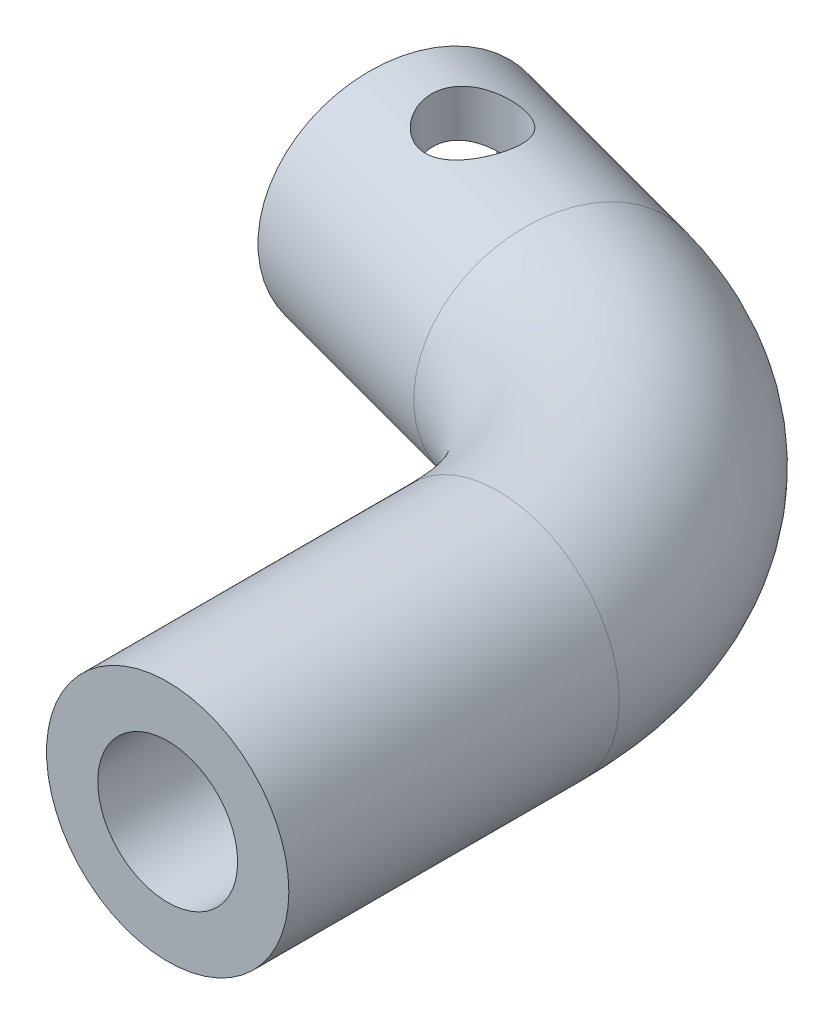
from build123d import *

# Parameters (mm, degrees)
SKETCH4_R           = 5.5
SKETCH6_R           = 3.175
HOLE_SHAFT_DEPTH    = 10
SKETCH7_R           = 3.4
HOLE_POT_DEPTH      = 10
SKETCH8_R           = 2
HOLE_INSERT_DEPTH   = 6.5000001
BOSS_EXTRUDE3_DEPTH = 1.5


with BuildPart() as part:
    # Sweep2: sweep along a path in PROFILE
    with BuildLine(Plane(origin=(0, 0, 0), x_dir=(1, 0, 0), z_dir=(0, 1, 0))) as sweep2_path:
        Line((2.5, -25), (2.5, -10))
        ThreePointArc((2.5, -10), (-0.172829853, -2.126097159), (-7.086656691, 2.49357424))
        Line((-7.086656691, 2.49357424), (-16.745914953, 5.081764691))
    # Sketch4 → Sweep2 (sweep)
    with BuildSketch(Plane.XY.offset(25)):
        with Locations((2.5, 0)):
            Circle(SKETCH4_R)
    sweep(path=sweep2_path.line)

    # Sketch6 → HOLE_SHAFT (cut)
    with BuildSketch(Plane.XY.offset(25)):
        with Locations((2.5, 0)):
            Circle(SKETCH6_R)
    extrude(amount=-HOLE_SHAFT_DEPTH, mode=Mode.SUBTRACT)

    # Sketch7 → HOLE_POT (cut)
    with BuildSketch(Plane(origin=(-16.894592529, 0, -4.526892425), x_dir=(-0.258819045, 0, 0.965925826), z_dir=(-0.965925826, 0, -0.258819045))):
        with Locations((-0.57444604, 0)):
            Circle(SKETCH7_R)
    extrude(amount=-HOLE_POT_DEPTH, mode=Mode.SUBTRACT)

    # Sketch8 → HOLE_INSERT (cut, through all)
    with BuildSketch(Plane(origin=(0, 0, 0), x_dir=(1, 0, 0), z_dir=(0, 1, 0))):
        with Locations((-12.643487424, 3.982522547)):
            Circle(SKETCH8_R)
    extrude(amount=HOLE_INSERT_DEPTH, mode=Mode.SUBTRACT)

    # Sketch11 → Boss-Extrude3 (add)
    with BuildSketch(Plane(origin=(-7.235334266, 0, -1.938701974), x_dir=(-0.258819045, 0, 0.965925826), z_dir=(-0.965925826, 0, -0.258819045))):
        with BuildLine():
            Line((-0.905457853, 3.383848575), (0.72667763, -3.141190411))
            ThreePointArc((0.72667763, -3.141190411), (0.250591719, -3.298380314), (-0.243434227, -3.383848575))
            Line((-0.243434227, -3.383848575), (-1.87556971, 3.141190411))
            ThreePointArc((-1.87556971, 3.141190411), (-1.3994838, 3.298380314), (-0.905457853, 3.383848575))
        make_face()
    extrude(amount=BOSS_EXTRUDE3_DEPTH)


solid = part.part
